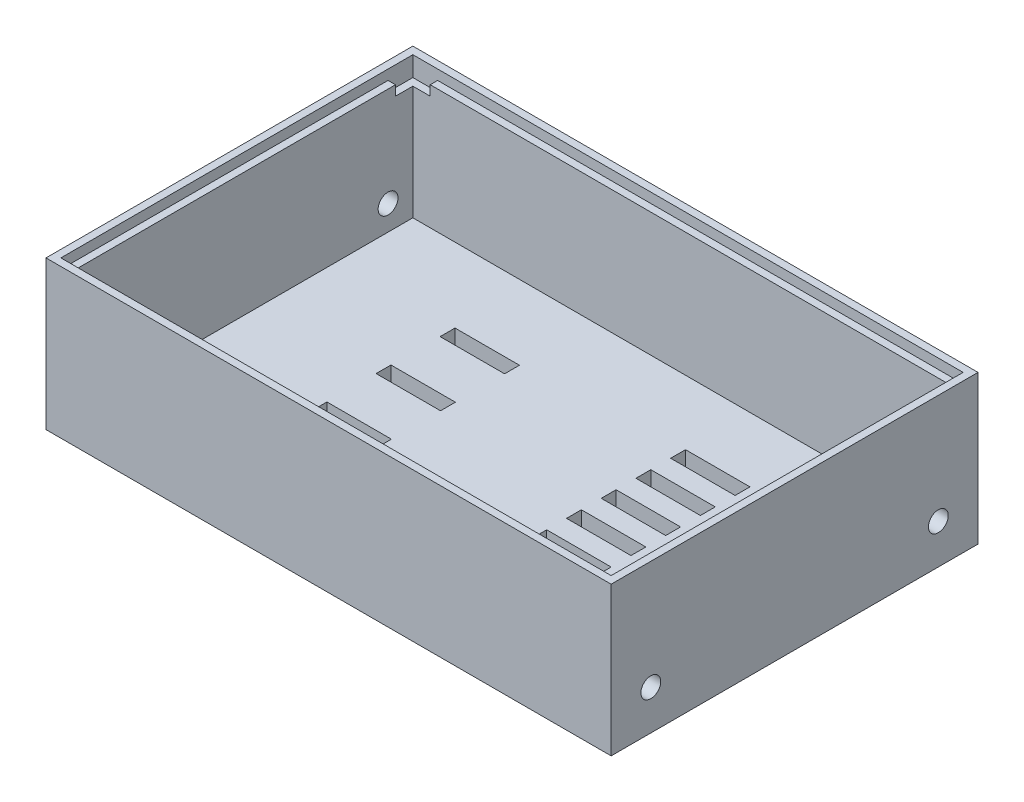
from build123d import *

# Parameters (mm, degrees)
SKETCH1_W                = 108
SKETCH1_H                = 68
BOSS_EXTRUDE1_DEPTH      = 3
SKETCH2_W                = 114
SKETCH2_H                = 74
SKETCH2_W_2              = 108
SKETCH2_H_2              = 68
BOSS_EXTRUDE2_DEPTH      = 25
BOSS_EXTRUDE2_DEPTH_BACK = 3
SKETCH4_W                = 114
SKETCH4_H                = 74
SKETCH4_W_2              = 111
SKETCH4_H_2              = 71
BOSS_EXTRUDE3_DEPTH      = 2
SKETCH5_R                = 2
CUT_EXTRUDE1_DEPTH       = 4
SKETCH6_W                = 13
SKETCH6_H                = 3
CUT_EXTRUDE2_DEPTH       = 31
MIRROR2_COPY_1_SKETCH_R  = 2
MIRROR2_COPY_1_DEPTH     = 4
SKETCH7_W                = 13
SKETCH7_H                = 3
CUT_EXTRUDE3_DEPTH       = 10
CUT_EXTRUDE4_DEPTH       = 2


with BuildPart() as part:
    # Sketch1 → Boss-Extrude1 (new body)
    with BuildSketch(Plane(origin=(0, 0, 0), x_dir=(1, 0, 0), z_dir=(0, 1, 0))):
        Rectangle(SKETCH1_W, SKETCH1_H)
    extrude(amount=BOSS_EXTRUDE1_DEPTH)

    # Sketch2 → Boss-Extrude2 (add, two sides)
    with BuildSketch(Plane(origin=(0, 3, 0), x_dir=(1, 0, 0), z_dir=(0, 1, 0))) as boss_extrude2_sk:
        Rectangle(SKETCH2_W, SKETCH2_H)
        Rectangle(SKETCH2_W_2, SKETCH2_H_2, mode=Mode.SUBTRACT)
    extrude(amount=BOSS_EXTRUDE2_DEPTH)
    extrude(boss_extrude2_sk.sketch, amount=-BOSS_EXTRUDE2_DEPTH_BACK)

    # Sketch4 → Boss-Extrude3 (add)
    with BuildSketch(Plane(origin=(0, 28, 0), x_dir=(1, 0, 0), z_dir=(0, 1, 0))):
        Rectangle(SKETCH4_W, SKETCH4_H)
        Rectangle(SKETCH4_W_2, SKETCH4_H_2, mode=Mode.SUBTRACT)
    extrude(amount=BOSS_EXTRUDE3_DEPTH)

    # Sketch5 → Cut-Extrude1 (cut, through all)
    with BuildSketch(Plane(origin=(-54, 0, 0), x_dir=(0, 0, -1), z_dir=(1, 0, 0))):
        with Locations((29, 8)):
            Circle(SKETCH5_R)
    cut_extrude1 = extrude(amount=-CUT_EXTRUDE1_DEPTH, mode=Mode.SUBTRACT)

    # Sketch6 → Cut-Extrude2 (cut, through all)
    with BuildSketch(Plane.XZ):
        with Locations((20.5, 22.5)):
            Rectangle(SKETCH6_W, SKETCH6_H)
        with Locations((37.5, 22.5)):
            Rectangle(SKETCH6_W, SKETCH6_H)
        with Locations((20.5, 15.5)):
            Rectangle(SKETCH6_W, SKETCH6_H)
        with Locations((37.5, 15.5)):
            Rectangle(SKETCH6_W, SKETCH6_H)
        with Locations((20.5, 8.5)):
            Rectangle(SKETCH6_W, SKETCH6_H)
        with Locations((37.5, 8.5)):
            Rectangle(SKETCH6_W, SKETCH6_H)
        with Locations((20.5, 1.5)):
            Rectangle(SKETCH6_W, SKETCH6_H)
        with Locations((37.5, 1.5)):
            Rectangle(SKETCH6_W, SKETCH6_H)
        with Locations((20.5, -5.5)):
            Rectangle(SKETCH6_W, SKETCH6_H)
        with Locations((37.5, -5.5)):
            Rectangle(SKETCH6_W, SKETCH6_H)
        with Locations((20.5, -12.5)):
            Rectangle(SKETCH6_W, SKETCH6_H)
        with Locations((37.5, -12.5)):
            Rectangle(SKETCH6_W, SKETCH6_H)
        with Locations((20.5, -19.5)):
            Rectangle(SKETCH6_W, SKETCH6_H)
        with Locations((37.5, -19.5)):
            Rectangle(SKETCH6_W, SKETCH6_H)
    extrude(amount=-CUT_EXTRUDE2_DEPTH, mode=Mode.SUBTRACT)

    # Mirror1: Cut-Extrude1 across plane
    add(cut_extrude1.mirror(Plane.XY), mode=Mode.SUBTRACT)

    # Mirror2: Cut-Extrude1 across plane
    add(cut_extrude1.mirror(Plane(origin=(0, 0, 0), x_dir=(0, 0, 1), z_dir=(1, 0, 0))), mode=Mode.SUBTRACT)

    # Mirror2 copy 1 sketch → Mirror2 copy 1 (cut, through all)
    with BuildSketch(Plane.ZY.offset(-54)):
        with Locations((29, 8)):
            Circle(MIRROR2_COPY_1_SKETCH_R)
    extrude(amount=-MIRROR2_COPY_1_DEPTH, mode=Mode.SUBTRACT)

    # Sketch7 → Cut-Extrude3 (cut)
    with BuildSketch(Plane(origin=(0, 3, 0), x_dir=(1, 0, 0), z_dir=(0, 1, 0))):
        with Locations((-24, 17.5)):
            Rectangle(SKETCH7_W, SKETCH7_H)
        with Locations((-24, 4.583391615)):
            Rectangle(SKETCH7_W, SKETCH7_H)
        with Locations((-24, -8.333216771)):
            Rectangle(SKETCH7_W, SKETCH7_H)
        with Locations((-24, -21.249825156)):
            Rectangle(SKETCH7_W, SKETCH7_H)
    extrude(amount=-CUT_EXTRUDE3_DEPTH, mode=Mode.SUBTRACT)

    # Sketch8 → Cut-Extrude4 (cut)
    with BuildSketch(Plane(origin=(0, 28, 0), x_dir=(1, 0, 0), z_dir=(0, 1, 0))):
        Polygon((-54, 34), (-50.5, 34), (-50.5, 35.5), (-55.5, 35.5), (-55.5, 30.5), (-54, 30.5), align=None)
        Polygon((54, -34), (54, -30.5), (55.5, -30.5), (55.5, -35.5), (50.5, -35.5), (50.5, -34), align=None)
    extrude(amount=-CUT_EXTRUDE4_DEPTH, mode=Mode.SUBTRACT)


solid = part.part
